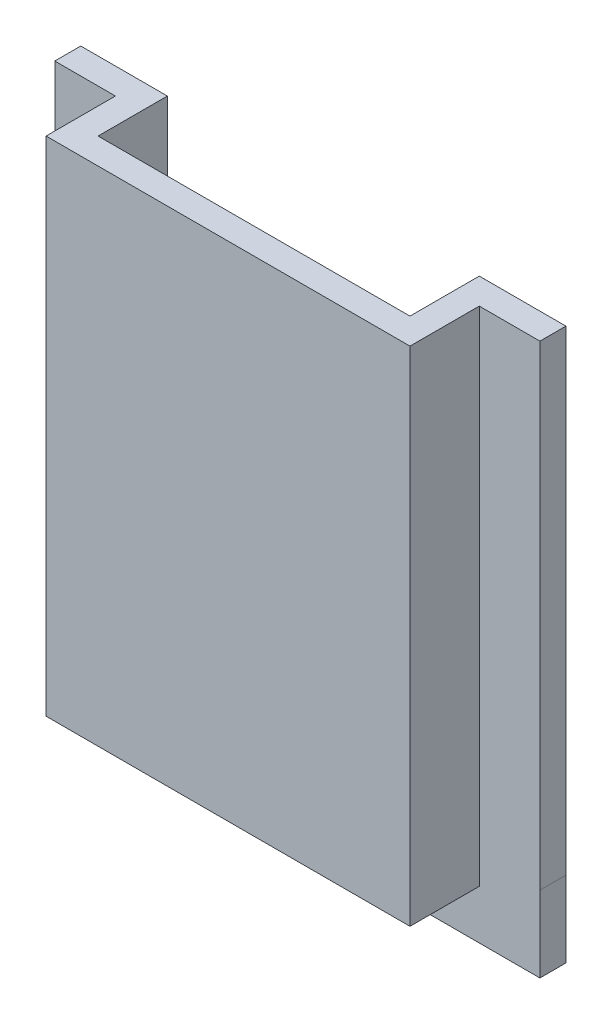
from build123d import *

# Parameters (mm, degrees)
SKETCH1_W           = 42
SKETCH1_H           = 58
BOSS_EXTRUDE1_DEPTH = 3
SKETCH2_W           = 3
SKETCH2_H           = 58
BOSS_EXTRUDE2_DEPTH = 8
SKETCH3_W           = 3
SKETCH3_H           = 58
BOSS_EXTRUDE3_DEPTH = 8
SKETCH4_W           = 36.040635574
SKETCH4_H           = 4.348824295
BOSS_EXTRUDE4_DEPTH = 8
SKETCH5_W           = 10
SKETCH5_H           = 53.666567446
BOSS_EXTRUDE5_DEPTH = 3
SKETCH6_W           = 10
SKETCH6_H           = 54.883518579
BOSS_EXTRUDE6_DEPTH = 3
SKETCH7_W           = 55.997152208
SKETCH7_H           = 10
BOSS_EXTRUDE7_DEPTH = 3


with BuildPart() as part:
    # Sketch1 → Boss-Extrude1 (new body)
    with BuildSketch(Plane.XY):
        with Locations((0, -1.5)):
            Rectangle(SKETCH1_W, SKETCH1_H)
    extrude(amount=BOSS_EXTRUDE1_DEPTH)

    # Sketch2 → Boss-Extrude2 (add)
    with BuildSketch(Plane(origin=(0, 0, 0), x_dir=(-1, 0, 0), z_dir=(0, 0, -1))):
        with Locations((-19.5, -1.5)):
            Rectangle(SKETCH2_W, SKETCH2_H)
    extrude(amount=BOSS_EXTRUDE2_DEPTH)

    # Sketch3 → Boss-Extrude3 (add)
    with BuildSketch(Plane(origin=(0, 0, 0), x_dir=(-1, 0, 0), z_dir=(0, 0, -1))):
        with Locations((19.5, -1.5)):
            Rectangle(SKETCH3_W, SKETCH3_H)
    extrude(amount=BOSS_EXTRUDE3_DEPTH)

    # Sketch4 → Boss-Extrude4 (add)
    with BuildSketch(Plane(origin=(0, 0, 0), x_dir=(-1, 0, 0), z_dir=(0, 0, -1))):
        with Locations((0.020317787, -28.325587852)):
            Rectangle(SKETCH4_W, SKETCH4_H)
    extrude(amount=BOSS_EXTRUDE4_DEPTH)

    # Sketch5 → Boss-Extrude5 (add)
    with BuildSketch(Plane(origin=(0, 0, -8), x_dir=(-1, 0, 0), z_dir=(0, 0, -1))):
        with Locations((23, 0.666716277)):
            Rectangle(SKETCH5_W, SKETCH5_H)
    extrude(amount=-BOSS_EXTRUDE5_DEPTH)

    # Sketch6 → Boss-Extrude6 (add)
    with BuildSketch(Plane(origin=(0, 0, -8), x_dir=(-1, 0, 0), z_dir=(0, 0, -1))):
        with Locations((-23, 0.05824071)):
            Rectangle(SKETCH6_W, SKETCH6_H)
    extrude(amount=-BOSS_EXTRUDE6_DEPTH)

    # Sketch7 → Boss-Extrude7 (add)
    with BuildSketch(Plane(origin=(0, 0, -8), x_dir=(-1, 0, 0), z_dir=(0, 0, -1))):
        with Locations((0.001423896, -31.166567446)):
            Rectangle(SKETCH7_W, SKETCH7_H)
    extrude(amount=-BOSS_EXTRUDE7_DEPTH)


solid = part.part
